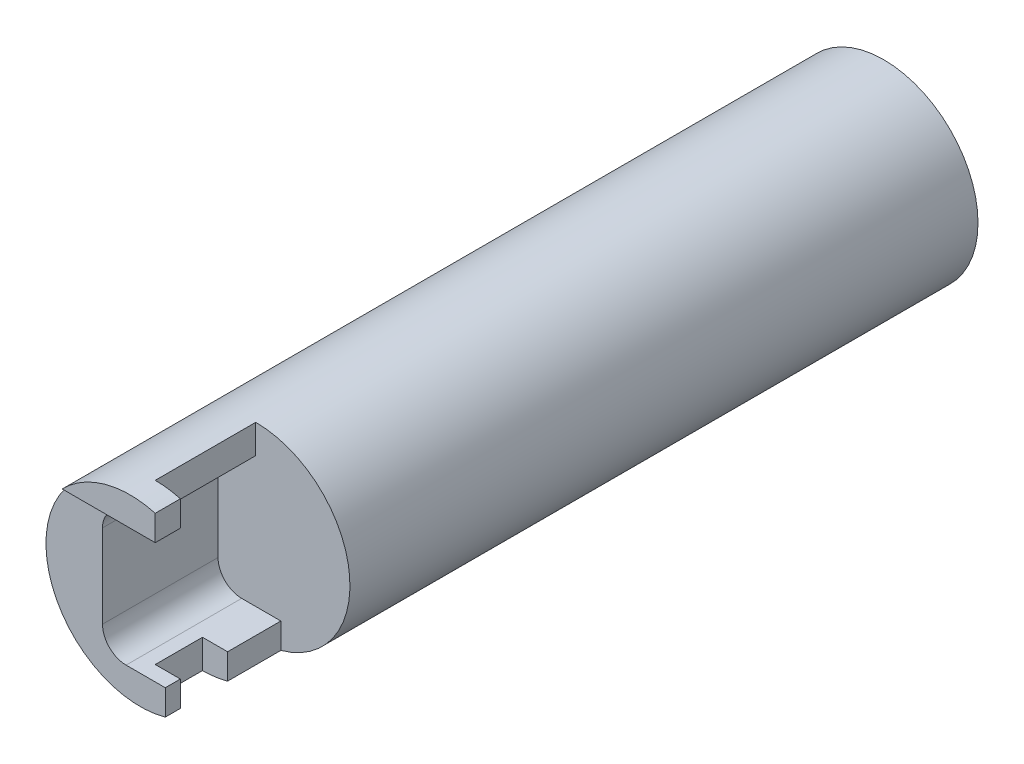
from build123d import *

# Parameters (mm, degrees)
SKETCH1_R      = 4.7625
EXTRUDE1_DEPTH = 38.1
EXTRUDE2_DEPTH = 6.35
SKETCH4_W      = 11.994523233
SKETCH4_H      = 10.10814551
EXTRUDE4_DEPTH = 0.508
EXTRUDE5_DEPTH = 1.27


with BuildPart() as part:
    # Sketch1 → Extrude1 (new body)
    with BuildSketch(Plane.XY):
        Circle(SKETCH1_R)
    extrude(amount=EXTRUDE1_DEPTH)

    # Sketch2 → Extrude2 (cut)
    with BuildSketch(Plane.XY.offset(38.1)):
        with BuildLine():
            Line((-0.7112, 3.302), (1.27, 3.302))
            Line((1.27, 3.302), (1.27, 10.556011527))
            Line((1.27, 10.556011527), (23.809552604, 10.556011527))
            Line((23.809552604, 10.556011527), (23.809552604, -10.556011527))
            Line((23.809552604, -10.556011527), (1.27, -10.556011527))
            Line((1.27, -10.556011527), (1.27, -3.302))
            Line((1.27, -3.302), (-0.7112, -3.302))
            ThreePointArc((-0.7112, -3.302), (-1.555344075, -2.952344075), (-1.905, -2.1082))
            Line((-1.905, -2.1082), (-1.905, 2.1082))
            ThreePointArc((-1.905, 2.1082), (-1.555344075, 2.952344075), (-0.7112, 3.302))
        make_face()
    extrude(amount=-EXTRUDE2_DEPTH, mode=Mode.SUBTRACT)

    # Sketch4 → Extrude4 (cut)
    with BuildSketch(Plane.XY.offset(38.1)):
        with Locations((-0.260671281, -1.752072755)):
            Rectangle(SKETCH4_W, SKETCH4_H)
    extrude(amount=-EXTRUDE4_DEPTH, mode=Mode.SUBTRACT)

    # Sketch5 → Extrude5 (cut)
    with BuildSketch(Plane(origin=(1.27, 0, 0), x_dir=(0, 0, -1), z_dir=(1, 0, 0))):
        Polygon((-36.83, 5.902578594), (-36.83, -11.457674659), (-34.4424, -11.457674659), (-34.4424, 3.302), (-31.75, 3.302), (-31.75, 5.902578594), align=None)
    extrude(amount=-EXTRUDE5_DEPTH, mode=Mode.SUBTRACT)


solid = part.part
